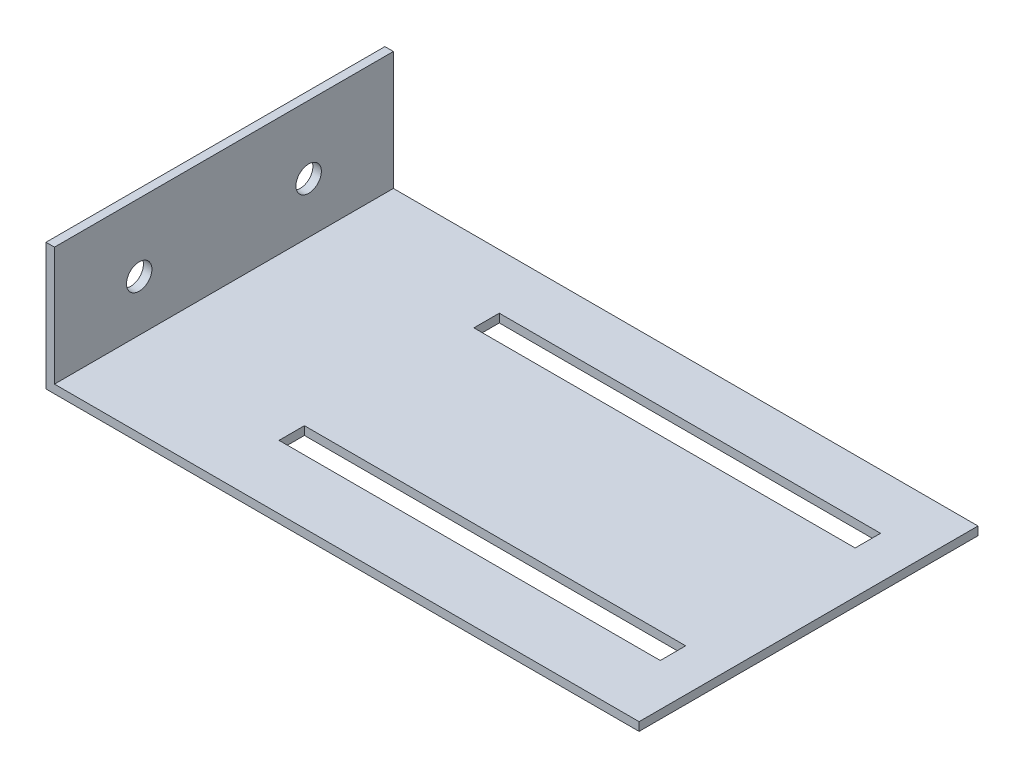
from build123d import *

# Parameters (mm, degrees)
BOSS_EXTRUDE1_DEPTH = 40
SKETCH2_W           = 45
SKETCH2_H           = 3
CUT_EXTRUDE1_DEPTH  = 10
SKETCH3_R           = 1.5
CUT_EXTRUDE2_DEPTH  = 10


with BuildPart() as part:
    # Sketch1 → Boss-Extrude1 (new body)
    with BuildSketch(Plane.XY):
        Polygon((0, 0), (70, 0), (70, 1), (1, 1), (1, 15), (0, 15), align=None)
    extrude(amount=BOSS_EXTRUDE1_DEPTH)

    # Sketch2 → Cut-Extrude1 (cut)
    with BuildSketch(Plane(origin=(0, 1, 0), x_dir=(1, 0, 0), z_dir=(0, 1, 0))):
        with Locations((42.5, -8)):
            Rectangle(SKETCH2_W, SKETCH2_H)
        with Locations((42.5, -31)):
            Rectangle(SKETCH2_W, SKETCH2_H)
    extrude(amount=-CUT_EXTRUDE1_DEPTH, mode=Mode.SUBTRACT)

    # Sketch3 → Cut-Extrude2 (cut)
    with BuildSketch(Plane.ZY):
        with Locations((30, 7)):
            Circle(SKETCH3_R)
        with Locations((10, 7)):
            Circle(SKETCH3_R)
    extrude(amount=-CUT_EXTRUDE2_DEPTH, mode=Mode.SUBTRACT)


solid = part.part
